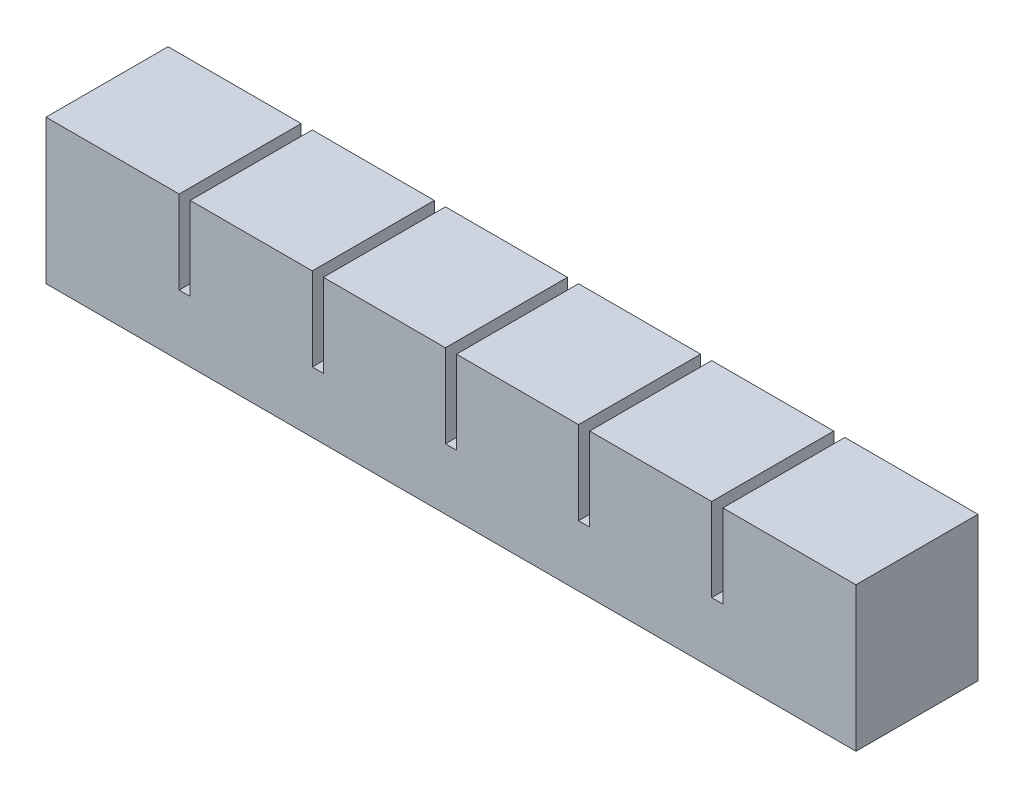
from build123d import *

# Parameters (mm, degrees)
SKETCH1_W           = 22
SKETCH1_H           = 20
BOSS_EXTRUDE1_DEPTH = 22
SKETCH2_W           = 12
SKETCH2_H           = 12
CUT_EXTRUDE1_DEPTH  = 15
SKETCH3_W           = 22
SKETCH3_H           = 5
BOSS_EXTRUDE2_DEPTH = 2
LPATTERN1_COUNT     = 6
LPATTERN1_PITCH     = 24
SKETCH4_W           = 22
SKETCH4_H           = 15
BOSS_EXTRUDE3_DEPTH = 2
SKETCH5_W           = 22
SKETCH5_H           = 20
BOSS_EXTRUDE4_DEPTH = 2
SKETCH6_W           = 132
SKETCH6_H           = 2
CUT_EXTRUDE2_DEPTH  = 2
SKETCH7_W           = 146
SKETCH7_H           = 22
BOSS_EXTRUDE5_DEPTH = 6


with BuildPart() as part:
    # Sketch1 → Boss-Extrude1 (new body)
    with BuildSketch(Plane.XY):
        with Locations((11, 10)):
            Rectangle(SKETCH1_W, SKETCH1_H)
    extrude(amount=BOSS_EXTRUDE1_DEPTH)

    # Sketch2 → Cut-Extrude1 (cut)
    with BuildSketch(Plane.XZ):
        with Locations((11, 11)):
            Rectangle(SKETCH2_W, SKETCH2_H)
    extrude(amount=-CUT_EXTRUDE1_DEPTH, mode=Mode.SUBTRACT)

    # Sketch3 → Boss-Extrude2 (add)
    with BuildSketch(Plane(origin=(22, 0, 0), x_dir=(0, 0, -1), z_dir=(1, 0, 0))):
        with Locations((-11, 2.5)):
            Rectangle(SKETCH3_W, SKETCH3_H)
    extrude(amount=BOSS_EXTRUDE2_DEPTH)


with BuildPart() as lpattern1_1:
    # LPattern1: pattern copy
    add(part.part.moved(Location(Vector(1, 0, 0) * (1 * LPATTERN1_PITCH))))


with BuildPart() as lpattern1_2:
    # LPattern1: pattern copy
    add(part.part.moved(Location(Vector(1, 0, 0) * (2 * LPATTERN1_PITCH))))


with BuildPart() as lpattern1_3:
    # LPattern1: pattern copy
    add(part.part.moved(Location(Vector(1, 0, 0) * (3 * LPATTERN1_PITCH))))


with BuildPart() as lpattern1_4:
    # LPattern1: pattern copy
    add(part.part.moved(Location(Vector(1, 0, 0) * (4 * LPATTERN1_PITCH))))


with BuildPart() as lpattern1_5:
    # LPattern1: pattern copy
    add(part.part.moved(Location(Vector(1, 0, 0) * (5 * LPATTERN1_PITCH))))


with BuildPart() as lpattern1_2_1:
    add(lpattern1_2.part)

    # Combine1: union LPattern1_3, LPattern1_4, LPattern1_5, LPattern1_1, part
    add(lpattern1_3.part)
    add(lpattern1_4.part)
    add(lpattern1_5.part)
    add(lpattern1_1.part)
    add(part.part)

    # Sketch4 → Boss-Extrude3 (add)
    with BuildSketch(Plane(origin=(142, 0, 0), x_dir=(0, 0, -1), z_dir=(1, 0, 0))):
        with Locations((-11, 12.5)):
            Rectangle(SKETCH4_W, SKETCH4_H)
    extrude(amount=BOSS_EXTRUDE3_DEPTH)

    # Sketch5 → Boss-Extrude4 (add)
    with BuildSketch(Plane.ZY):
        with Locations((11, 10)):
            Rectangle(SKETCH5_W, SKETCH5_H)
    extrude(amount=BOSS_EXTRUDE4_DEPTH)

    # Sketch6 → Cut-Extrude2 (cut)
    with BuildSketch(Plane(origin=(0, 0, 0), x_dir=(-1, 0, 0), z_dir=(0, -1, 0))):
        with Locations((-71, -11)):
            Rectangle(SKETCH6_W, SKETCH6_H)
    extrude(amount=-CUT_EXTRUDE2_DEPTH, mode=Mode.SUBTRACT)

    # Sketch7 → Boss-Extrude5 (add)
    with BuildSketch(Plane(origin=(0, 0, 0), x_dir=(-1, 0, 0), z_dir=(0, -1, 0))):
        with Locations((-71, -11)):
            Rectangle(SKETCH7_W, SKETCH7_H)
    extrude(amount=BOSS_EXTRUDE5_DEPTH)


solid = lpattern1_2_1.part
